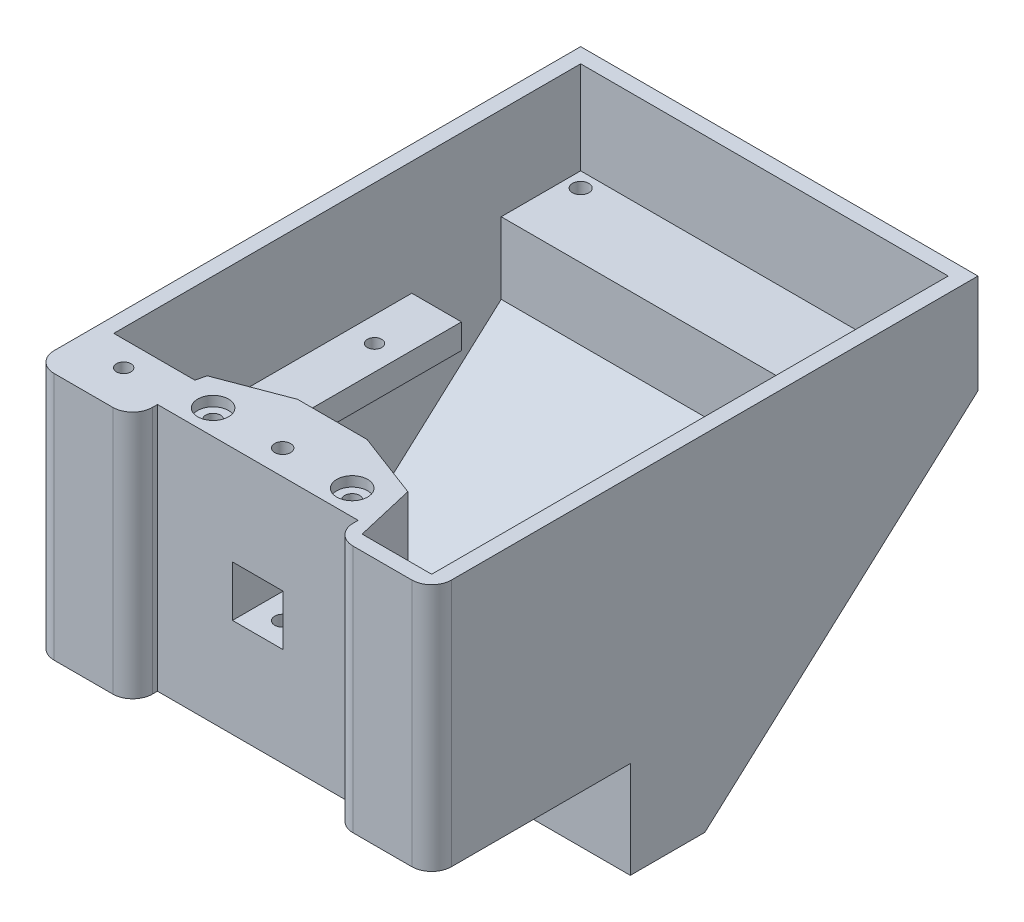
from build123d import *

# Parameters (mm, degrees)
BOSS_EXTRUDE1_DEPTH = 80
SHELL1_T            = -3
SKETCH3_W           = 46
SKETCH3_H           = 47
BOSS_EXTRUDE2_DEPTH = 17
SKETCH4_W           = 10.2
SKETCH4_H           = 10.2
CUT_EXTRUDE1_DEPTH  = 20
SKETCH6_W           = 15
SKETCH6_H           = 12.8
CUT_EXTRUDE2_DEPTH  = 3
SKETCH7_W           = 40.4
SKETCH7_H           = 50
CUT_EXTRUDE3_DEPTH  = 5
FILLET1_R           = 4
CUT_EXTRUDE7_DEPTH  = 47
SKETCH13_R          = 1.5
CUT_EXTRUDE8_DEPTH  = 25
SKETCH14_R          = 3.1
CUT_EXTRUDE9_DEPTH  = 2
SKETCH17_W          = 45
SKETCH17_H          = 5
BOSS_EXTRUDE5_DEPTH = 74
CUT_EXTRUDE10_REACH = 48.51
SKETCH18_W          = 54
SKETCH18_H          = 45
CUT_EXTRUDE11_REACH = 48.51
SKETCH19_R          = 1.45
BOSS_EXTRUDE6_DEPTH = 47
SKETCH22_R          = 1.45
CUT_EXTRUDE12_DEPTH = 70.509632224
BOSS_EXTRUDE7_DEPTH = 74
SKETCH27_R          = 1.65
CUT_EXTRUDE14_DEPTH = 10
CUT_EXTRUDE15_START = -3
CUT_EXTRUDE15_DEPTH = 32
CUT_EXTRUDE16_DEPTH = 30
BOSS_EXTRUDE8_DEPTH = 20
SKETCH31_R          = 1.5
CUT_EXTRUDE17_DEPTH = 43.509632224
CUT_EXTRUDE18_DEPTH = 15
CUT_EXTRUDE19_REACH = 48.51
SKETCH33_W          = 10
SKETCH33_H          = 5
SKETCH34_R          = 1.6
CUT_EXTRUDE20_DEPTH = 70.509632224
CUT_EXTRUDE22_DEPTH = 14


with BuildPart() as part:
    # Sketch2 → Boss-Extrude1 (new body)
    with BuildSketch(Plane(origin=(0, 0, 0), x_dir=(0, 0, -1), z_dir=(1, 0, 0))):
        Polygon((-27.320490368, 20.998248687), (-27.320490368, -29.001751313), (12.679509632, -29.001751313), (12.679509632, -48.511383538), (27.679509632, -48.511383538), (82.679509632, 0.998248687), (82.679509632, 20.998248687), align=None)
    extrude(amount=BOSS_EXTRUDE1_DEPTH)

    # Shell1
    shell1_openings = [part.faces().sort_by_distance(p)[0] for p in [
        (40, 20.998248687, -27.679509632),
    ]]
    offset(amount=SHELL1_T, openings=shell1_openings, kind=Kind.INTERSECTION)

    # Sketch3 → Boss-Extrude2 (add)
    with BuildSketch(Plane(origin=(0, 0, 24.320490368), x_dir=(-1, 0, 0), z_dir=(0, 0, -1))):
        with Locations((-40, -2.501751313)):
            Rectangle(SKETCH3_W, SKETCH3_H)
    extrude(amount=BOSS_EXTRUDE2_DEPTH)

    # Sketch4 → Cut-Extrude1 (cut)
    with BuildSketch(Plane.XY.offset(27.320490368)):
        with Locations((40, -4.001751313)):
            Rectangle(SKETCH4_W, SKETCH4_H)
    extrude(amount=-CUT_EXTRUDE1_DEPTH, mode=Mode.SUBTRACT)

    # Sketch6 → Cut-Extrude2 (cut)
    with BuildSketch(Plane.XZ.offset(29.001751313)):
        with Locations((51.5, 0.920490368)):
            Rectangle(SKETCH6_W, SKETCH6_H)
        with Locations((28.5, 0.920490368)):
            Rectangle(SKETCH6_W, SKETCH6_H)
    extrude(amount=-CUT_EXTRUDE2_DEPTH, mode=Mode.SUBTRACT)

    # Sketch7 → Cut-Extrude3 (cut)
    with BuildSketch(Plane.XY.offset(27.320490368)):
        with Locations((40, -4.001751313)):
            Rectangle(SKETCH7_W, SKETCH7_H)
    extrude(amount=-CUT_EXTRUDE3_DEPTH, mode=Mode.SUBTRACT)

    # Fillet1
    fillet1_edges = [part.edges().sort_by_distance(p)[0] for p in [
        (19.8, -4.001751313, 27.320490368),
        (60.2, -4.001751313, 27.320490368),
        (80, -4.001751313, 27.320490368),
        (0, -4.001751313, 27.320490368),
    ]]
    fillet(fillet1_edges, radius=FILLET1_R)

    # Sketch12 → Cut-Extrude7 (cut)
    with BuildSketch(Plane(origin=(0, 20.998248687, 0), x_dir=(1, 0, 0), z_dir=(0, 1, 0))):
        Polygon((33, -7.320490368), (19.8, -12.320490368), (17, -24.320490368), (17, -7.320490368), align=None)
        Polygon((47, -7.320490368), (63, -7.320490368), (63, -24.320490368), (60.2, -12.320490368), align=None)
    extrude(amount=-CUT_EXTRUDE7_DEPTH, mode=Mode.SUBTRACT)

    # Sketch13 → Cut-Extrude8 (cut)
    with BuildSketch(Plane(origin=(0, 20.998248687, 0), x_dir=(1, 0, 0), z_dir=(0, 1, 0))):
        with Locations((26, -17.320490368)):
            Circle(SKETCH13_R)
        with Locations((54, -17.320490368)):
            Circle(SKETCH13_R)
    extrude(amount=-CUT_EXTRUDE8_DEPTH, mode=Mode.SUBTRACT)

    # Sketch14 → Cut-Extrude9 (cut)
    with BuildSketch(Plane(origin=(0, 20.998248687, 0), x_dir=(1, 0, 0), z_dir=(0, 1, 0))):
        with Locations((26, -17.320490368)):
            Circle(SKETCH14_R)
        with Locations((54, -17.320490368)):
            Circle(SKETCH14_R)
    extrude(amount=-CUT_EXTRUDE9_DEPTH, mode=Mode.SUBTRACT)

    # Sketch17 → Boss-Extrude5 (add)
    with BuildSketch(Plane.ZY.offset(-77)):
        with Locations((-23.179509632, -4.501751313)):
            Rectangle(SKETCH17_W, SKETCH17_H)
    extrude(amount=BOSS_EXTRUDE5_DEPTH)

    # Sketch18 → Cut-Extrude10 (cut, up to next)
    with BuildSketch(Plane(origin=(0, -2.001751313, 0), x_dir=(1, 0, 0), z_dir=(0, 1, 0)), mode=Mode.PRIVATE) as cut_extrude10_sk1:
        with Locations((40, 23.179509632)):
            Rectangle(SKETCH18_W, SKETCH18_H)
    cut_extrude10_tool1 = extrude(cut_extrude10_sk1.sketch, amount=-CUT_EXTRUDE10_REACH, mode=Mode.PRIVATE) & part.part
    add(cut_extrude10_tool1.solids().sort_by_distance((40, -2.001751, -23.17951))[0], mode=Mode.SUBTRACT)

    # Sketch19 → Cut-Extrude11 (cut, up to next)
    with BuildSketch(Plane(origin=(0, -2.001751313, 0), x_dir=(1, 0, 0), z_dir=(0, 1, 0)), mode=Mode.PRIVATE) as cut_extrude11_sk1:
        with Locations((72, 37.179509632)):
            Circle(SKETCH19_R)
    cut_extrude11_tool1 = extrude(cut_extrude11_sk1.sketch, amount=-CUT_EXTRUDE11_REACH, mode=Mode.PRIVATE) & part.part
    add(cut_extrude11_tool1.solids().sort_by_distance((72, -2.001751, -37.17951))[0], mode=Mode.SUBTRACT)
    # Sketch19 → Cut-Extrude11 (cut, up to next)
    with BuildSketch(Plane(origin=(0, -2.001751313, 0), x_dir=(1, 0, 0), z_dir=(0, 1, 0)), mode=Mode.PRIVATE) as cut_extrude11_sk2:
        with Locations((72, 6.179509632)):
            Circle(SKETCH19_R)
    cut_extrude11_tool2 = extrude(cut_extrude11_sk2.sketch, amount=-CUT_EXTRUDE11_REACH, mode=Mode.PRIVATE) & part.part
    add(cut_extrude11_tool2.solids().sort_by_distance((72, -2.001751, -6.17951))[0], mode=Mode.SUBTRACT)
    # Sketch19 → Cut-Extrude11 (cut, up to next)
    with BuildSketch(Plane(origin=(0, -2.001751313, 0), x_dir=(1, 0, 0), z_dir=(0, 1, 0)), mode=Mode.PRIVATE) as cut_extrude11_sk3:
        with Locations((8, 33.179509632)):
            Circle(SKETCH19_R)
    cut_extrude11_tool3 = extrude(cut_extrude11_sk3.sketch, amount=-CUT_EXTRUDE11_REACH, mode=Mode.PRIVATE) & part.part
    add(cut_extrude11_tool3.solids().sort_by_distance((8, -2.001751, -33.17951))[0], mode=Mode.SUBTRACT)
    # Sketch19 → Cut-Extrude11 (cut, up to next)
    with BuildSketch(Plane(origin=(0, -2.001751313, 0), x_dir=(1, 0, 0), z_dir=(0, 1, 0)), mode=Mode.PRIVATE) as cut_extrude11_sk4:
        with Locations((8, 6.179509632)):
            Circle(SKETCH19_R)
    cut_extrude11_tool4 = extrude(cut_extrude11_sk4.sketch, amount=-CUT_EXTRUDE11_REACH, mode=Mode.PRIVATE) & part.part
    add(cut_extrude11_tool4.solids().sort_by_distance((8, -2.001751, -6.17951))[0], mode=Mode.SUBTRACT)

    # Sketch21 → Boss-Extrude6 (add)
    with BuildSketch(Plane(origin=(0, -26.001751313, 0), x_dir=(1, 0, 0), z_dir=(0, 1, 0))):
        Polygon((3, -24.320490368), (3, -14.320490368), (19.333333333, -14.320490368), (17, -24.320490368), align=None)
    extrude(amount=BOSS_EXTRUDE6_DEPTH)

    # Sketch22 → Cut-Extrude12 (cut, through all)
    with BuildSketch(Plane(origin=(0, 20.998248687, 0), x_dir=(1, 0, 0), z_dir=(0, 1, 0))):
        with Locations((10, -19.320490368)):
            Circle(SKETCH22_R)
    extrude(amount=-CUT_EXTRUDE12_DEPTH, mode=Mode.SUBTRACT)

    # Sketch26 → Boss-Extrude7 (add)
    with BuildSketch(Plane(origin=(3, 0, 0), x_dir=(0, 0, -1), z_dir=(1, 0, 0))):
        Polygon((79.679509632, 2.334161996), (63.679509632, 2.334161996), (63.679509632, -12.068640106), align=None)
    extrude(amount=BOSS_EXTRUDE7_DEPTH)

    # Sketch27 → Cut-Extrude14 (cut)
    with BuildSketch(Plane(origin=(0, 2.334161996, 0), x_dir=(1, 0, 0), z_dir=(0, 1, 0))):
        with Locations((6, 76.679509632)):
            Circle(SKETCH27_R)
        with Locations((74, 76.679509632)):
            Circle(SKETCH27_R)
    extrude(amount=-CUT_EXTRUDE14_DEPTH, mode=Mode.SUBTRACT)

    # Sketch28 → Cut-Extrude15 (cut)
    with BuildSketch(Plane(origin=(0, 2.334161996, 0), x_dir=(1, 0, 0), z_dir=(0, 1, 0)).offset(CUT_EXTRUDE15_START)):
        Polygon((74, 79.929509632), (71.185417438, 78.304509632), (71.185417438, 75.054509632), (74, 73.429509632), (76.814582562, 75.054509632), (76.814582562, 78.304509632), align=None)
        Polygon((6, 73.429509632), (8.814582562, 75.054509632), (8.814582562, 78.304509632), (6, 79.929509632), (3.185417438, 78.304509632), (3.185417438, 75.054509632), align=None)
    extrude(amount=-CUT_EXTRUDE15_DEPTH, mode=Mode.SUBTRACT)

    # Sketch29 → Cut-Extrude16 (cut)
    with BuildSketch(Plane.XZ.offset(29.001751313)):
        Polygon((7.185417438, 17.695490368), (10, 16.070490368), (12.814582562, 17.695490368), (12.814582562, 20.945490368), (10, 22.570490368), (7.185417438, 20.945490368), align=None)
    extrude(amount=-CUT_EXTRUDE16_DEPTH, mode=Mode.SUBTRACT)

    # Sketch30 → Boss-Extrude8 (add)
    with BuildSketch(Plane(origin=(0, -26.001751313, 0), x_dir=(1, 0, 0), z_dir=(0, 1, 0))):
        Polygon((77, -24.320490368), (63, -24.320490368), (60.2, -12.320490368), (77, -12.320490368), align=None)
    extrude(amount=BOSS_EXTRUDE8_DEPTH)

    # Sketch31 → Cut-Extrude17 (cut, through all)
    with BuildSketch(Plane(origin=(0, -6.001751313, 0), x_dir=(1, 0, 0), z_dir=(0, 1, 0))):
        with Locations((72, -21.320490368)):
            Circle(SKETCH31_R)
    extrude(amount=-CUT_EXTRUDE17_DEPTH, mode=Mode.SUBTRACT)

    # Sketch32 → Cut-Extrude18 (cut)
    with BuildSketch(Plane.XZ.offset(29.001751313)):
        Polygon((72, 24.570490368), (69.185417438, 22.945490368), (69.185417438, 19.695490368), (72, 18.070490368), (74.814582562, 19.695490368), (74.814582562, 22.945490368), align=None)
    extrude(amount=-CUT_EXTRUDE18_DEPTH, mode=Mode.SUBTRACT)

    # Sketch33 → Cut-Extrude19 (cut, up to next)
    with BuildSketch(Plane(origin=(0, -2.001751313, 0), x_dir=(1, 0, 0), z_dir=(0, 1, 0)), mode=Mode.PRIVATE) as cut_extrude19_sk1:
        with Locations((72, 43.179509632)):
            Rectangle(SKETCH33_W, SKETCH33_H)
    cut_extrude19_tool1 = extrude(cut_extrude19_sk1.sketch, amount=-CUT_EXTRUDE19_REACH, mode=Mode.PRIVATE) & part.part
    add(cut_extrude19_tool1.solids().sort_by_distance((72, -2.001751, -43.17951))[0], mode=Mode.SUBTRACT)

    # Sketch34 → Cut-Extrude20 (cut, through all)
    with BuildSketch(Plane(origin=(0, 20.998248687, 0), x_dir=(1, 0, 0), z_dir=(0, 1, 0))):
        with Locations((40, -17.320490368)):
            Circle(SKETCH34_R)
    extrude(amount=-CUT_EXTRUDE20_DEPTH, mode=Mode.SUBTRACT)

    # Sketch36 → Cut-Extrude22 (cut)
    with BuildSketch(Plane.XZ.offset(29.001751313)):
        Polygon((38.375, 20.13507293), (36.75, 17.320490368), (38.375, 14.505907805), (41.625, 14.505907805), (43.25, 17.320490368), (41.625, 20.13507293), align=None)
    extrude(amount=-CUT_EXTRUDE22_DEPTH, mode=Mode.SUBTRACT)


solid = part.part
